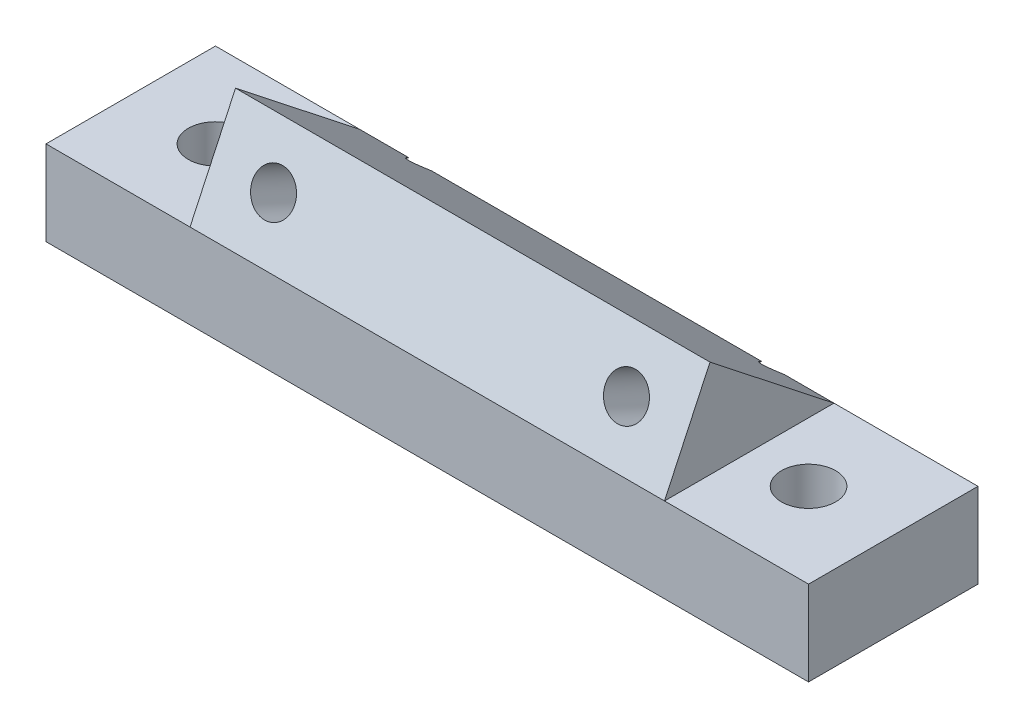
from build123d import *

# Parameters (mm, degrees)
SKETCH1_W           = 45
SKETCH1_H           = 10
SKETCH1_R           = 1.6
BOSS_EXTRUDE2_DEPTH = 5
BOSS_EXTRUDE3_DEPTH = 14
SKETCH4_R           = 1.25
CUT_EXTRUDE1_DEPTH  = 28


with BuildPart() as part:
    # Sketch1 → Boss-Extrude2 (new body)
    with BuildSketch(Plane(origin=(0, 0, 0), x_dir=(1, 0, 0), z_dir=(0, 1, 0))):
        Rectangle(SKETCH1_W, SKETCH1_H)
        with Locations((-17.5, 0)):
            Circle(SKETCH1_R, mode=Mode.SUBTRACT)
        with Locations((17.5, 0)):
            Circle(SKETCH1_R, mode=Mode.SUBTRACT)
    extrude(amount=BOSS_EXTRUDE2_DEPTH)

    # Sketch3 → Boss-Extrude3 (add, symmetric)
    with BuildSketch(Plane(origin=(0, 0, 0), x_dir=(0, 0, -1), z_dir=(1, 0, 0))):
        Polygon((-5, 5), (5, 5), (-2.316374038, 10.755054448), align=None)
    extrude(amount=BOSS_EXTRUDE3_DEPTH, both=True)

    # Sketch4 → Cut-Extrude1 (cut)
    with BuildSketch(Plane(origin=(0, 2.808142084, 6.022080132), x_dir=(1, 0, 0), z_dir=(0, 0.422618262, 0.906307787))):
        with Locations((-10.414, 5.593447626)):
            Circle(SKETCH4_R)
        with Locations((10.414, 5.593447626)):
            Circle(SKETCH4_R)
    extrude(amount=-CUT_EXTRUDE1_DEPTH, mode=Mode.SUBTRACT)


solid = part.part
